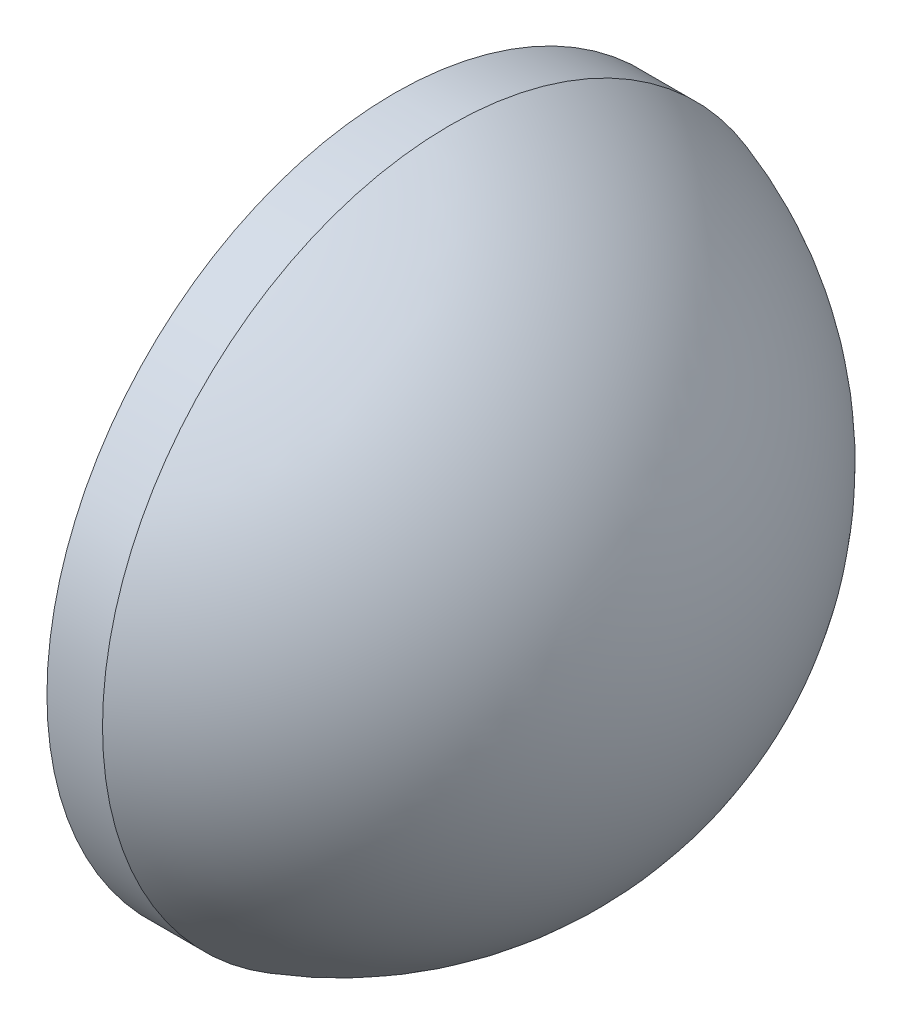
from build123d import *


with BuildPart() as part:
    # 草图1 → 旋转1 (revolve)
    with BuildSketch(Plane.XY):
        with BuildLine():
            Line((205.284407954, -102.691436271), (205.284407954, -90.191436271))
            Line((205.284407954, -90.191436271), (207.284407954, -90.191436271))
            ThreePointArc((207.284407954, -90.191436271), (213.909273224, -94.942959002), (216.444407954, -102.691436271))
            Line((216.444407954, -102.691436271), (205.284407954, -102.691436271))
        make_face()
    revolve(axis=Axis((203.772376712, -102.691436271, 0), (1, 0, 0)))


solid = part.part
